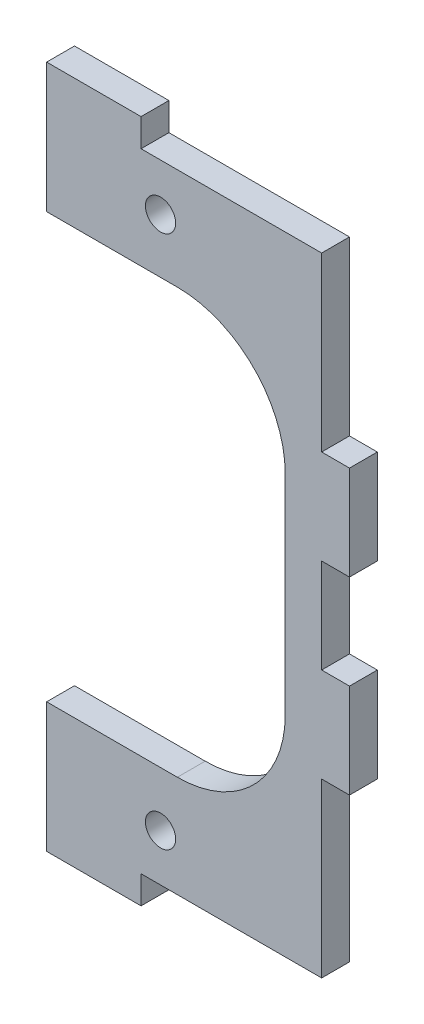
from build123d import *

# Parameters (mm, degrees)
SKETCH1_W           = 10
SKETCH1_H           = 2.95
BOSS_EXTRUDE1_DEPTH = 2.95
CUT_EXTRUDE1_DEPTH  = 3.95
FILLET1_R           = 11.43
SKETCH3_W           = 2.95
SKETCH3_H           = 10
BOSS_EXTRUDE2_DEPTH = 2.95
SKETCH4_R           = 1.6
CUT_EXTRUDE2_DEPTH  = 3.95


with BuildPart() as part:
    # Sketch1 → Boss-Extrude1 (new body)
    with BuildSketch(Plane.XY):
        Polygon((-2.065, 0), (-12.065, 0), (-12.065, -66.508), (-2.065, -66.508), (17.065, -66.508), (17.065, 0), align=None)
        with Locations((-7.065, 1.475)):
            Rectangle(SKETCH1_W, SKETCH1_H)
        with Locations((-7.065, -67.983)):
            Rectangle(SKETCH1_W, SKETCH1_H)
    extrude(amount=BOSS_EXTRUDE1_DEPTH)

    # Sketch2 → Cut-Extrude1 (cut, through all)
    with BuildSketch(Plane.XY.offset(2.95)):
        Polygon((13.208, -10.773769685), (12.346170522, -10.773769685), (-7.346170522, -55.734230315), (13.208, -55.734230315), align=None)
        Polygon((-7.346170522, -55.734230315), (12.346170522, -10.773769685), (-12.065, -10.773769685), (-12.065, -55.734230315), align=None)
    extrude(amount=-CUT_EXTRUDE1_DEPTH, mode=Mode.SUBTRACT)

    # Fillet1
    fillet1_edges = [part.edges().sort_by_distance(p)[0] for p in [
        (13.208, -10.773769685, 1.475),
        (13.208, -55.734230315, 1.475),
    ]]
    fillet(fillet1_edges, radius=FILLET1_R)

    # Sketch3 → Boss-Extrude2 (add)
    with BuildSketch(Plane.XY.offset(2.95)):
        with BuildLine():
            Line((17.065, -48.254), (17.065, -38.254))
            Line((17.065, -38.254), (17.065, -28.254))
            Line((17.065, -28.254), (17.065, -18.254))
            Line((17.065, -18.254), (12.503866838, -18.254))
            ThreePointArc((12.503866838, -18.254), (13.030589879, -20.197748494), (13.208, -22.203769685))
            Line((13.208, -22.203769685), (13.208, -44.304230315))
            ThreePointArc((13.208, -44.304230315), (13.030589879, -46.310251506), (12.503866838, -48.254))
            Line((12.503866838, -48.254), (17.065, -48.254))
        make_face()
        with Locations((18.54, -23.254)):
            Rectangle(SKETCH3_W, SKETCH3_H)
        with Locations((18.54, -43.254)):
            Rectangle(SKETCH3_W, SKETCH3_H)
    extrude(amount=-BOSS_EXTRUDE2_DEPTH)

    # Sketch4 → Cut-Extrude2 (cut, through all)
    with BuildSketch(Plane.XY.offset(2.95)):
        with Locations((0, -61.508)):
            Circle(SKETCH4_R)
        with Locations((0, -5)):
            Circle(SKETCH4_R)
    extrude(amount=-CUT_EXTRUDE2_DEPTH, mode=Mode.SUBTRACT)


solid = part.part
